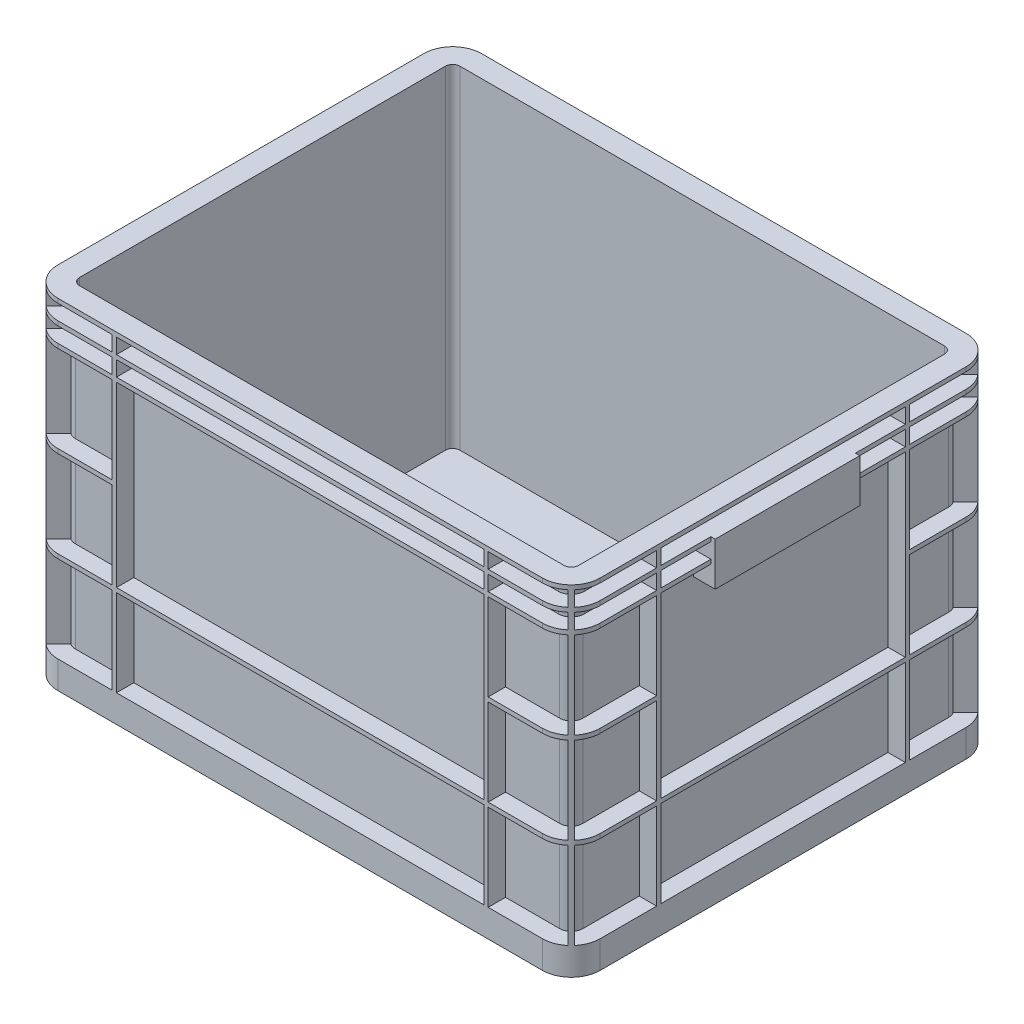
from build123d import *

# Parameters (mm, degrees)
SKETCH1_W                 = 375
SKETCH1_H                 = 293
BOSS_EXTRUDE1_DEPTH       = 240
FILLET1_R                 = 20
CUT_EXTRUDE1_DEPTH        = 230
CUT_EXTRUDE2_DEPTH        = 5
CUT_EXTRUDE3_DEPTH        = 5
CUT_EXTRUDE4_DEPTH        = 60
CUT_EXTRUDE5_DEPTH        = 60
CUT_EXTRUDE6_DEPTH        = 60
CUT_EXTRUDE12_DEPTH       = 10.5
CUT_EXTRUDE13_DEPTH       = 10.5
SKETCH10_W                = 15
SKETCH10_H                = 3
SKETCH10_W_2              = 3
SKETCH10_H_2              = 15
BOSS_EXTRUDE2_DEPTH       = 216
MIRROR2_COPY_1_SKETCH_W   = 15
MIRROR2_COPY_1_SKETCH_H   = 3
MIRROR2_COPY_1_SKETCH_W_2 = 3
MIRROR2_COPY_1_SKETCH_H_2 = 15
MIRROR2_COPY_1_DEPTH      = 216
SKETCH11_W                = 254
SKETCH11_H                = 12
CUT_EXTRUDE7_DEPTH        = 42
SKETCH12_W                = 12
SKETCH12_H                = 169
CUT_EXTRUDE8_DEPTH        = 42
SKETCH13_W                = 254
SKETCH13_H                = 12
CUT_EXTRUDE9_DEPTH        = 42
SKETCH14_W                = 12
SKETCH14_H                = 169
CUT_EXTRUDE10_DEPTH       = 42
SKETCH19_W                = 100
SKETCH19_H                = 30
BOSS_EXTRUDE3_DEPTH       = 15
SKETCH20_W                = 100
SKETCH20_H                = 30
BOSS_EXTRUDE4_DEPTH       = 3
SKETCH21_W                = 12
SKETCH21_H                = 94
CUT_EXTRUDE14_DEPTH       = 25


with BuildPart() as part:
    # Sketch1 → Boss-Extrude1 (new body)
    with BuildSketch(Plane(origin=(0, 0, 0), x_dir=(1, 0, 0), z_dir=(0, 1, 0))):
        with Locations((187.5, 146.5)):
            Rectangle(SKETCH1_W, SKETCH1_H)
    extrude(amount=BOSS_EXTRUDE1_DEPTH)

    # Fillet1
    fillet1_edges = [part.edges().sort_by_distance(p)[0] for p in [
        (0, 120, -293),
        (375, 120, -293),
        (375, 120, 0),
        (0, 120, 0),
    ]]
    fillet(fillet1_edges, radius=FILLET1_R)

    # Sketch2 → Cut-Extrude1 (cut)
    with BuildSketch(Plane(origin=(0, 240, 0), x_dir=(1, 0, 0), z_dir=(0, 1, 0))):
        with BuildLine():
            Line((355, 278), (20, 278))
            ThreePointArc((20, 278), (16.464466094, 276.535533906), (15, 273))
            Line((15, 273), (15, 20))
            ThreePointArc((15, 20), (16.464466094, 16.464466094), (20, 15))
            Line((20, 15), (355, 15))
            ThreePointArc((355, 15), (358.535533906, 16.464466094), (360, 20))
            Line((360, 20), (360, 273))
            ThreePointArc((360, 273), (358.535533906, 276.535533906), (355, 278))
        make_face()
    extrude(amount=-CUT_EXTRUDE1_DEPTH, mode=Mode.SUBTRACT)

    # Sketch3 → Cut-Extrude2 (cut)
    with BuildSketch(Plane.XZ):
        with BuildLine():
            Line((0, -20), (0, -273))
            ThreePointArc((0, -273), (5.857864376, -287.142135624), (20, -293))
            Line((20, -293), (355, -293))
            ThreePointArc((355, -293), (369.142135624, -287.142135624), (375, -273))
            Line((375, -273), (375, -20))
            ThreePointArc((375, -20), (369.142135624, -5.857864376), (355, 0))
            Line((355, 0), (20, 0))
            ThreePointArc((20, 0), (5.857864376, -5.857864376), (0, -20))
        make_face()
        with BuildLine():
            Line((365, -273), (365, -20))
            ThreePointArc((365, -20), (362.071067812, -12.928932188), (355, -10))
            Line((355, -10), (20, -10))
            ThreePointArc((20, -10), (12.928932188, -12.928932188), (10, -20))
            Line((10, -20), (10, -273))
            ThreePointArc((10, -273), (12.928932188, -280.071067812), (20, -283))
            Line((20, -283), (355, -283))
            ThreePointArc((355, -283), (362.071067812, -280.071067812), (365, -273))
        make_face(mode=Mode.SUBTRACT)
    extrude(amount=-CUT_EXTRUDE2_DEPTH, mode=Mode.SUBTRACT)

    # Sketch4 → Cut-Extrude3 (cut)
    with BuildSketch(Plane.XZ):
        with BuildLine():
            Line((15, -20), (15, -273))
            ThreePointArc((15, -273), (16.464466094, -276.535533906), (20, -278))
            Line((20, -278), (355, -278))
            ThreePointArc((355, -278), (358.535533906, -276.535533906), (360, -273))
            Line((360, -273), (360, -20))
            ThreePointArc((360, -20), (358.535533906, -16.464466094), (355, -15))
            Line((355, -15), (20, -15))
            ThreePointArc((20, -15), (16.464466094, -16.464466094), (15, -20))
        make_face()
    extrude(amount=-CUT_EXTRUDE3_DEPTH, mode=Mode.SUBTRACT)

    # Sketch5 → Cut-Extrude4 (cut)
    with BuildSketch(Plane(origin=(0, 210, 0), x_dir=(1, 0, 0), z_dir=(0, 1, 0))):
        with BuildLine():
            Line((355, 293), (20, 293))
            ThreePointArc((20, 293), (5.857864376, 287.142135624), (0, 273))
            Line((0, 273), (0, 20))
            ThreePointArc((0, 20), (5.857864376, 5.857864376), (20, 0))
            Line((20, 0), (355, 0))
            ThreePointArc((355, 0), (369.142135624, 5.857864376), (375, 20))
            Line((375, 20), (375, 273))
            ThreePointArc((375, 273), (369.142135624, 287.142135624), (355, 293))
        make_face()
        with BuildLine():
            Line((355, 281), (20, 281))
            ThreePointArc((20, 281), (14.343145751, 278.656854249), (12, 273))
            Line((12, 273), (12, 20))
            ThreePointArc((12, 20), (14.343145751, 14.343145751), (20, 12))
            Line((20, 12), (355, 12))
            ThreePointArc((355, 12), (360.656854249, 14.343145751), (363, 20))
            Line((363, 20), (363, 273))
            ThreePointArc((363, 273), (360.656854249, 278.656854249), (355, 281))
        make_face(mode=Mode.SUBTRACT)
    extrude(amount=-CUT_EXTRUDE4_DEPTH, mode=Mode.SUBTRACT)

    # Sketch7 → Cut-Extrude5 (cut)
    with BuildSketch(Plane(origin=(0, 147, 0), x_dir=(1, 0, 0), z_dir=(0, 1, 0))):
        with BuildLine():
            Line((355, 293), (20, 293))
            ThreePointArc((20, 293), (5.857864376, 287.142135624), (0, 273))
            Line((0, 273), (0, 20))
            ThreePointArc((0, 20), (5.857864376, 5.857864376), (20, 0))
            Line((20, 0), (355, 0))
            ThreePointArc((355, 0), (369.142135624, 5.857864376), (375, 20))
            Line((375, 20), (375, 273))
            ThreePointArc((375, 273), (369.142135624, 287.142135624), (355, 293))
        make_face()
        with BuildLine():
            Line((20, 12), (355, 12))
            ThreePointArc((355, 12), (360.656854249, 14.343145751), (363, 20))
            Line((363, 20), (363, 273))
            ThreePointArc((363, 273), (360.656854249, 278.656854249), (355, 281))
            Line((355, 281), (20, 281))
            ThreePointArc((20, 281), (14.343145751, 278.656854249), (12, 273))
            Line((12, 273), (12, 20))
            ThreePointArc((12, 20), (14.343145751, 14.343145751), (20, 12))
        make_face(mode=Mode.SUBTRACT)
    extrude(amount=-CUT_EXTRUDE5_DEPTH, mode=Mode.SUBTRACT)

    # Sketch8 → Cut-Extrude6 (cut)
    with BuildSketch(Plane(origin=(0, 84, 0), x_dir=(1, 0, 0), z_dir=(0, 1, 0))):
        with BuildLine():
            Line((355, 293), (20, 293))
            ThreePointArc((20, 293), (5.857864376, 287.142135624), (0, 273))
            Line((0, 273), (0, 20))
            ThreePointArc((0, 20), (5.857864376, 5.857864376), (20, 0))
            Line((20, 0), (355, 0))
            ThreePointArc((355, 0), (369.142135624, 5.857864376), (375, 20))
            Line((375, 20), (375, 273))
            ThreePointArc((375, 273), (369.142135624, 287.142135624), (355, 293))
        make_face()
        with BuildLine():
            Line((363, 20), (363, 273))
            ThreePointArc((363, 273), (360.656854249, 278.656854249), (355, 281))
            Line((355, 281), (20, 281))
            ThreePointArc((20, 281), (14.343145751, 278.656854249), (12, 273))
            Line((12, 273), (12, 20))
            ThreePointArc((12, 20), (14.343145751, 14.343145751), (20, 12))
            Line((20, 12), (355, 12))
            ThreePointArc((355, 12), (360.656854249, 14.343145751), (363, 20))
        make_face(mode=Mode.SUBTRACT)
    extrude(amount=-CUT_EXTRUDE6_DEPTH, mode=Mode.SUBTRACT)

    # Sketch16 → Cut-Extrude12 (cut)
    with BuildSketch(Plane(origin=(0, 237, 0), x_dir=(1, 0, 0), z_dir=(0, 1, 0))):
        with BuildLine():
            Line((355, 293), (20, 293))
            ThreePointArc((20, 293), (5.857864376, 287.142135624), (0, 273))
            Line((0, 273), (0, 20))
            ThreePointArc((0, 20), (5.857864376, 5.857864376), (20, 0))
            Line((20, 0), (355, 0))
            ThreePointArc((355, 0), (369.142135624, 5.857864376), (375, 20))
            Line((375, 20), (375, 273))
            ThreePointArc((375, 273), (369.142135624, 287.142135624), (355, 293))
        make_face()
        with BuildLine():
            Line((355, 282), (20, 282))
            ThreePointArc((20, 282), (13.636038969, 279.363961031), (11, 273))
            Line((11, 273), (11, 20))
            ThreePointArc((11, 20), (13.636038969, 13.636038969), (20, 11))
            Line((20, 11), (355, 11))
            ThreePointArc((355, 11), (361.363961031, 13.636038969), (364, 20))
            Line((364, 20), (364, 273))
            ThreePointArc((364, 273), (361.363961031, 279.363961031), (355, 282))
        make_face(mode=Mode.SUBTRACT)
    extrude(amount=-CUT_EXTRUDE12_DEPTH, mode=Mode.SUBTRACT)

    # Sketch17 → Cut-Extrude13 (cut)
    with BuildSketch(Plane(origin=(0, 223.5, 0), x_dir=(1, 0, 0), z_dir=(0, 1, 0))):
        with BuildLine():
            Line((355, 293), (20, 293))
            ThreePointArc((20, 293), (5.857864376, 287.142135624), (0, 273))
            Line((0, 273), (0, 20))
            ThreePointArc((0, 20), (5.857864376, 5.857864376), (20, 0))
            Line((20, 0), (355, 0))
            ThreePointArc((355, 0), (369.142135624, 5.857864376), (375, 20))
            Line((375, 20), (375, 273))
            ThreePointArc((375, 273), (369.142135624, 287.142135624), (355, 293))
        make_face()
        with BuildLine():
            Line((355, 282), (20, 282))
            ThreePointArc((20, 282), (13.636038969, 279.363961031), (11, 273))
            Line((11, 273), (11, 20))
            ThreePointArc((11, 20), (13.636038969, 13.636038969), (20, 11))
            Line((20, 11), (355, 11))
            ThreePointArc((355, 11), (361.363961031, 13.636038969), (364, 20))
            Line((364, 20), (364, 273))
            ThreePointArc((364, 273), (361.363961031, 279.363961031), (355, 282))
        make_face(mode=Mode.SUBTRACT)
    extrude(amount=-CUT_EXTRUDE13_DEPTH, mode=Mode.SUBTRACT)

    # Sketch10 → Boss-Extrude2 (add)
    with BuildSketch(Plane(origin=(0, 240, 0), x_dir=(1, 0, 0), z_dir=(0, 1, 0))):
        with Locations((7.5, 232.5)):
            Rectangle(SKETCH10_W, SKETCH10_H)
        with BuildLine():
            ThreePointArc((15.566655437, 275.312024219), (16.464466094, 276.535533906), (17.687975781, 277.433344563))
            Line((17.687975781, 277.433344563), (6.958355396, 288.162964948))
            ThreePointArc((6.958355396, 288.162964948), (5.857864376, 287.142135624), (4.837035052, 286.041644604))
            Line((4.837035052, 286.041644604), (15.566655437, 275.312024219))
        make_face()
        with Locations((59, 285.5)):
            Rectangle(SKETCH10_W_2, SKETCH10_H_2)
    boss_extrude2 = extrude(amount=-BOSS_EXTRUDE2_DEPTH)

    # Mirror1: Boss-Extrude2 across plane
    add(boss_extrude2.mirror(Plane.XY.offset(-146.5)))

    # Mirror2: Boss-Extrude2 across plane
    add(boss_extrude2.mirror(Plane(origin=(187.5, 0, 0), x_dir=(0, 0, 1), z_dir=(1, 0, 0))))

    # Mirror2 copy 1 sketch → Mirror2 copy 1 (add)
    with BuildSketch(Plane(origin=(375, 240, -293), x_dir=(-1, 0, 0), z_dir=(0, 1, 0))):
        with Locations((7.5, 232.5)):
            Rectangle(MIRROR2_COPY_1_SKETCH_W, MIRROR2_COPY_1_SKETCH_H)
        with BuildLine():
            ThreePointArc((15.566655437, 275.312024219), (16.464466094, 276.535533906), (17.687975781, 277.433344563))
            Line((17.687975781, 277.433344563), (6.958355396, 288.162964948))
            ThreePointArc((6.958355396, 288.162964948), (5.857864376, 287.142135624), (4.837035052, 286.041644604))
            Line((4.837035052, 286.041644604), (15.566655437, 275.312024219))
        make_face()
        with Locations((59, 285.5)):
            Rectangle(MIRROR2_COPY_1_SKETCH_W_2, MIRROR2_COPY_1_SKETCH_H_2)
    extrude(amount=-MIRROR2_COPY_1_DEPTH)

    # Sketch11 → Cut-Extrude7 (cut)
    with BuildSketch(Plane(origin=(0, 150, 0), x_dir=(1, 0, 0), z_dir=(0, 1, 0))):
        with Locations((187.5, 6)):
            Rectangle(SKETCH11_W, SKETCH11_H)
    extrude(amount=-CUT_EXTRUDE7_DEPTH, mode=Mode.SUBTRACT)

    # Sketch12 → Cut-Extrude8 (cut)
    with BuildSketch(Plane(origin=(0, 150, 0), x_dir=(1, 0, 0), z_dir=(0, 1, 0))):
        with Locations((6, 146.5)):
            Rectangle(SKETCH12_W, SKETCH12_H)
    extrude(amount=-CUT_EXTRUDE8_DEPTH, mode=Mode.SUBTRACT)

    # Sketch13 → Cut-Extrude9 (cut)
    with BuildSketch(Plane(origin=(0, 150, 0), x_dir=(1, 0, 0), z_dir=(0, 1, 0))):
        with Locations((187.5, 287)):
            Rectangle(SKETCH13_W, SKETCH13_H)
    extrude(amount=-CUT_EXTRUDE9_DEPTH, mode=Mode.SUBTRACT)

    # Sketch14 → Cut-Extrude10 (cut)
    with BuildSketch(Plane(origin=(0, 150, 0), x_dir=(1, 0, 0), z_dir=(0, 1, 0))):
        with Locations((369, 146.5)):
            Rectangle(SKETCH14_W, SKETCH14_H)
    extrude(amount=-CUT_EXTRUDE10_DEPTH, mode=Mode.SUBTRACT)

    # Sketch19 → Boss-Extrude3 (add)
    with BuildSketch(Plane.ZY):
        with Locations((-146.5, 211.5)):
            Rectangle(SKETCH19_W, SKETCH19_H)
    boss_extrude3 = extrude(amount=-BOSS_EXTRUDE3_DEPTH)

    # Sketch20 → Boss-Extrude4 (add)
    with BuildSketch(Plane.ZY):
        with Locations((-146.5, 211.5)):
            Rectangle(SKETCH20_W, SKETCH20_H)
    boss_extrude4 = extrude(amount=BOSS_EXTRUDE4_DEPTH)

    # Sketch21 → Cut-Extrude14 (cut)
    with BuildSketch(Plane.XZ.offset(-196.5)):
        with Locations((6, -146.5)):
            Rectangle(SKETCH21_W, SKETCH21_H)
    cut_extrude14 = extrude(amount=-CUT_EXTRUDE14_DEPTH, mode=Mode.SUBTRACT)

    # Mirror3: Boss-Extrude3, Boss-Extrude4, Cut-Extrude14 across plane
    add(boss_extrude3.mirror(Plane(origin=(187.5, 0, 0), x_dir=(0, 0, 1), z_dir=(1, 0, 0))))
    add(boss_extrude4.mirror(Plane(origin=(187.5, 0, 0), x_dir=(0, 0, 1), z_dir=(1, 0, 0))))
    add(cut_extrude14.mirror(Plane(origin=(187.5, 0, 0), x_dir=(0, 0, 1), z_dir=(1, 0, 0))), mode=Mode.SUBTRACT)


solid = part.part
